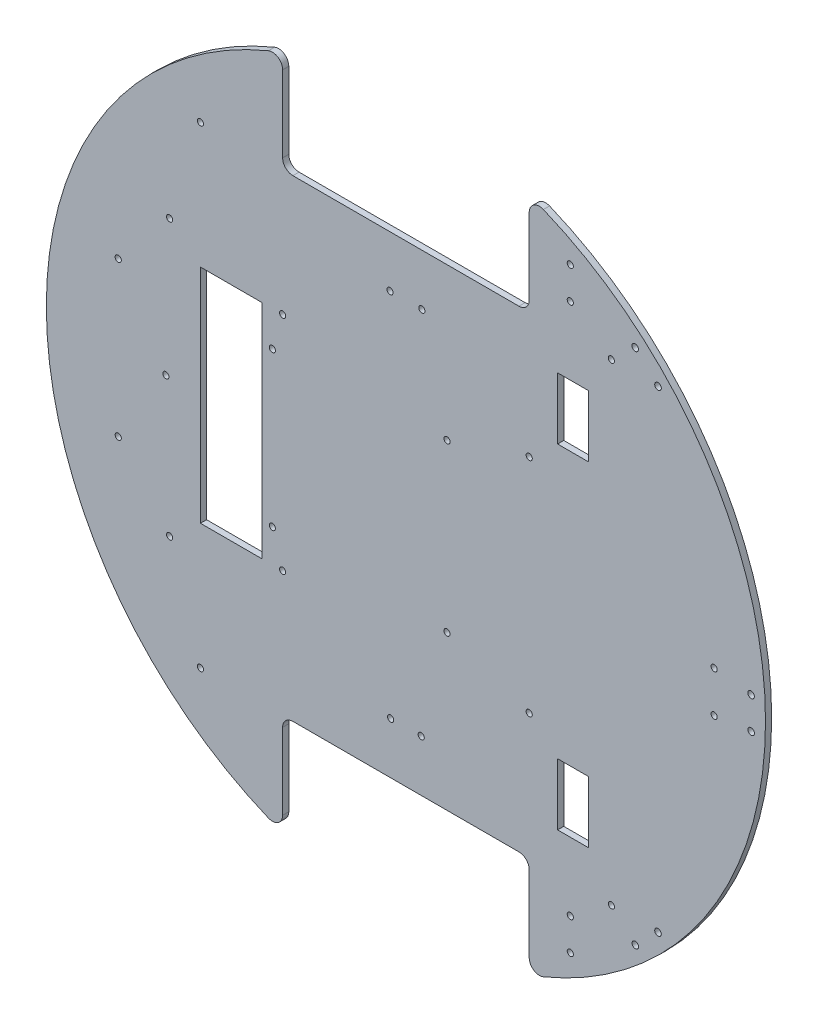
from build123d import *

# Parameters (mm, degrees)
SKETCH_1_R             = 175
EXTRUDE_1_DEPTH        = 3
CUT_EXTRUDE_1_DEPTH    = 3
FILLET_1_R             = 5
FILLET_2_R             = 5
FILLET_3_R             = 5
SKETCH_5_R             = 1.5
CUT_EXTRUDE_4_DEPTH    = 3
SKETCH_6_R             = 1.5
CUT_EXTRUDE_5_DEPTH    = 3
SKETCH_7_W             = 30
SKETCH_7_H             = 108
CUT_EXTRUDE_6_DEPTH    = 3
SKETCH_8_R             = 1.5
CUT_EXTRUDE_7_DEPTH    = 3
SKETCH_9_R             = 1.5
CUT_EXTRUDE_8_DEPTH    = 10
SKETCH_10_R            = 1.6
CUT_EXTRUDE_9_DEPTH    = 10
SKETCH_11_W            = 15
SKETCH_11_H            = 30
CUT_EXTRUDE_10_DEPTH   = 10
SKETCH_17_R            = 1.5
CUT_EXTRUDE_12_DEPTH   = 4
SKETCH_29_R            = 1.5
CUT_EXTRUDE_6879_DEPTH = 4
SKETCH_30_R            = 1.5
CUT_EXTRUDE_7056_DEPTH = 4
SKETCH_31_R            = 1.5
CUT_EXTRUDE_7256_DEPTH = 4
SKETCH_32_R            = 1.5
WEB_DEPTH              = 4


with BuildPart() as part:
    # ｽｹｯﾁ1 → ﾎﾞｽ - 押し出し1 (new body)
    with BuildSketch(Plane.XY):
        Circle(SKETCH_1_R)
    extrude(amount=EXTRUDE_1_DEPTH)

    # ｽｹｯﾁ2 → ｶｯﾄ - 押し出し1 (cut)
    with BuildSketch(Plane.XY.offset(3)):
        with BuildLine():
            Line((-60, 115), (0, 115))
            Line((0, 115), (0, 175))
            ThreePointArc((0, 175), (-30.465194158, 172.327803749), (-60, 164.392822228))
            Line((-60, 164.392822228), (-60, 115))
        make_face()
        with BuildLine():
            Line((0, 175), (0, 115))
            Line((0, 115), (60, 115))
            Line((60, 115), (60, 164.392822228))
            ThreePointArc((60, 164.392822228), (30.465194158, 172.327803749), (0, 175))
        make_face()
        with BuildLine():
            Line((0, -175), (0, -115))
            Line((0, -115), (-60, -115))
            Line((-60, -115), (-60, -164.392822228))
            ThreePointArc((-60, -164.392822228), (-30.465194158, -172.327803749), (0, -175))
        make_face()
        with BuildLine():
            Line((60, -115), (0, -115))
            Line((0, -115), (0, -175))
            ThreePointArc((0, -175), (30.465194158, -172.327803749), (60, -164.392822228))
            Line((60, -164.392822228), (60, -115))
        make_face()
    extrude(amount=-CUT_EXTRUDE_1_DEPTH, mode=Mode.SUBTRACT)

    # ﾌｨﾚｯﾄ1
    fillet_1_edges = [part.edges().sort_by_distance(p)[0] for p in [
        (-60, 164.392822228, 1.5),
    ]]
    fillet(fillet_1_edges, radius=FILLET_1_R)

    # ﾌｨﾚｯﾄ2
    fillet_2_edges = [part.edges().sort_by_distance(p)[0] for p in [
        (-60, 115, 1.5),
        (60, 164.392822228, 1.5),
        (60, 115, 1.5),
    ]]
    fillet(fillet_2_edges, radius=FILLET_2_R)

    # ﾌｨﾚｯﾄ3
    fillet_3_edges = [part.edges().sort_by_distance(p)[0] for p in [
        (-60, -115, 1.5),
        (60, -115, 1.5),
        (60, -164.392822228, 1.5),
        (-60, -164.392822228, 1.5),
    ]]
    fillet(fillet_3_edges, radius=FILLET_3_R)

    # ｽｹｯﾁ5 → ｶｯﾄ - 押し出し4 (cut)
    with BuildSketch(Plane.XY.offset(3)):
        with Locations((-100, -115)):
            Circle(SKETCH_5_R)
        with Locations((100, -115)):
            Circle(SKETCH_5_R)
        with Locations((100, 115)):
            Circle(SKETCH_5_R)
        with Locations((-100, 115)):
            Circle(SKETCH_5_R)
    extrude(amount=-CUT_EXTRUDE_4_DEPTH, mode=Mode.SUBTRACT)

    # ｽｹｯﾁ6 → ｶｯﾄ - 押し出し5 (cut)
    with BuildSketch(Plane.XY.offset(3)):
        with Locations((-60, 54)):
            Circle(SKETCH_6_R)
        with Locations((60, 54)):
            Circle(SKETCH_6_R)
        with Locations((-60, -54)):
            Circle(SKETCH_6_R)
        with Locations((60, -54)):
            Circle(SKETCH_6_R)
    extrude(amount=-CUT_EXTRUDE_5_DEPTH, mode=Mode.SUBTRACT)

    # ｽｹｯﾁ7 → ｶｯﾄ - 押し出し6 (cut)
    with BuildSketch(Plane.XY.offset(3)):
        with Locations((-85, 0)):
            Rectangle(SKETCH_7_W, SKETCH_7_H)
    extrude(amount=-CUT_EXTRUDE_6_DEPTH, mode=Mode.SUBTRACT)

    # ｽｹｯﾁ8 → ｶｯﾄ - 押し出し7 (cut)
    with BuildSketch(Plane.XY.offset(3)):
        with Locations((-115, -67)):
            Circle(SKETCH_8_R)
        with Locations((-116.822468618, 0)):
            Circle(SKETCH_8_R)
        with Locations((-115, 67)):
            Circle(SKETCH_8_R)
    extrude(amount=-CUT_EXTRUDE_7_DEPTH, mode=Mode.SUBTRACT)

    # ｽｹｯﾁ9 → ｶｯﾄ - 押し出し8 (cut)
    with BuildSketch(Plane.XY.offset(3)):
        with Locations((-65, 37)):
            Circle(SKETCH_9_R)
        with Locations((20, 41)):
            Circle(SKETCH_9_R)
        with Locations((-65, -38)):
            Circle(SKETCH_9_R)
        with Locations((20, -40)):
            Circle(SKETCH_9_R)
    extrude(amount=-CUT_EXTRUDE_8_DEPTH, mode=Mode.SUBTRACT)

    # ｽｹｯﾁ10 → ｶｯﾄ - 押し出し9 (cut)
    with BuildSketch(Plane.XY.offset(3)):
        with Locations((111.643659725, -125.921059639)):
            Circle(SKETCH_10_R)
        with Locations((122.679794489, -115.037952538)):
            Circle(SKETCH_10_R)
        with Locations((168, 7.75)):
            Circle(SKETCH_10_R)
        with Locations((168, -7.75)):
            Circle(SKETCH_10_R)
        with Locations((111.56768007, 125.844011632)):
            Circle(SKETCH_10_R)
        with Locations((122.679794489, 115.037952538)):
            Circle(SKETCH_10_R)
    extrude(amount=-CUT_EXTRUDE_9_DEPTH, mode=Mode.SUBTRACT)

    # ｽｹｯﾁ11 → ｶｯﾄ - 押し出し10 (cut)
    with BuildSketch(Plane.XY.offset(3)):
        with Locations((81.317279836, 81.317279836)):
            Rectangle(SKETCH_11_W, SKETCH_11_H)
        with Locations((81.317279836, -81.317279836)):
            Rectangle(SKETCH_11_W, SKETCH_11_H)
    extrude(amount=-CUT_EXTRUDE_10_DEPTH, mode=Mode.SUBTRACT)

    # ｽｹｯﾁ17 → ｶｯﾄ - 押し出し12 (cut, through all)
    with BuildSketch(Plane.XY.offset(3)):
        with Locations((-7.75, 90)):
            Circle(SKETCH_17_R)
        with Locations((7.75, 90)):
            Circle(SKETCH_17_R)
        with Locations((7.45, -90)):
            Circle(SKETCH_17_R)
        with Locations((-7.45, -90)):
            Circle(SKETCH_17_R)
    extrude(amount=-CUT_EXTRUDE_12_DEPTH, mode=Mode.SUBTRACT)

    # ｽｹｯﾁ29 → Cut-Extrude 6879 (cut, through all)
    with BuildSketch(Plane.XY.offset(3)):
        with Locations((80, 145)):
            Circle(SKETCH_29_R)
        with Locations((80, 129.5)):
            Circle(SKETCH_29_R)
    extrude(amount=-CUT_EXTRUDE_6879_DEPTH, mode=Mode.SUBTRACT)

    # ｽｹｯﾁ30 → Cut-Extrude 7056 (cut, through all)
    with BuildSketch(Plane.XY.offset(3)):
        with Locations((80, -129.5)):
            Circle(SKETCH_30_R)
        with Locations((80, -145)):
            Circle(SKETCH_30_R)
    extrude(amount=-CUT_EXTRUDE_7056_DEPTH, mode=Mode.SUBTRACT)

    # ｽｹｯﾁ31 → Cut-Extrude 7256 (cut, through all)
    with BuildSketch(Plane.XY.offset(3)):
        with Locations((-140, 37.5)):
            Circle(SKETCH_31_R)
        with Locations((-140, -37.5)):
            Circle(SKETCH_31_R)
    extrude(amount=-CUT_EXTRUDE_7256_DEPTH, mode=Mode.SUBTRACT)

    # ｽｹｯﾁ32 → WEBカメラ (cut, through all)
    with BuildSketch(Plane.XY.offset(3)):
        with Locations((150, 10)):
            Circle(SKETCH_32_R)
        with Locations((150, -10)):
            Circle(SKETCH_32_R)
    extrude(amount=-WEB_DEPTH, mode=Mode.SUBTRACT)


solid = part.part
